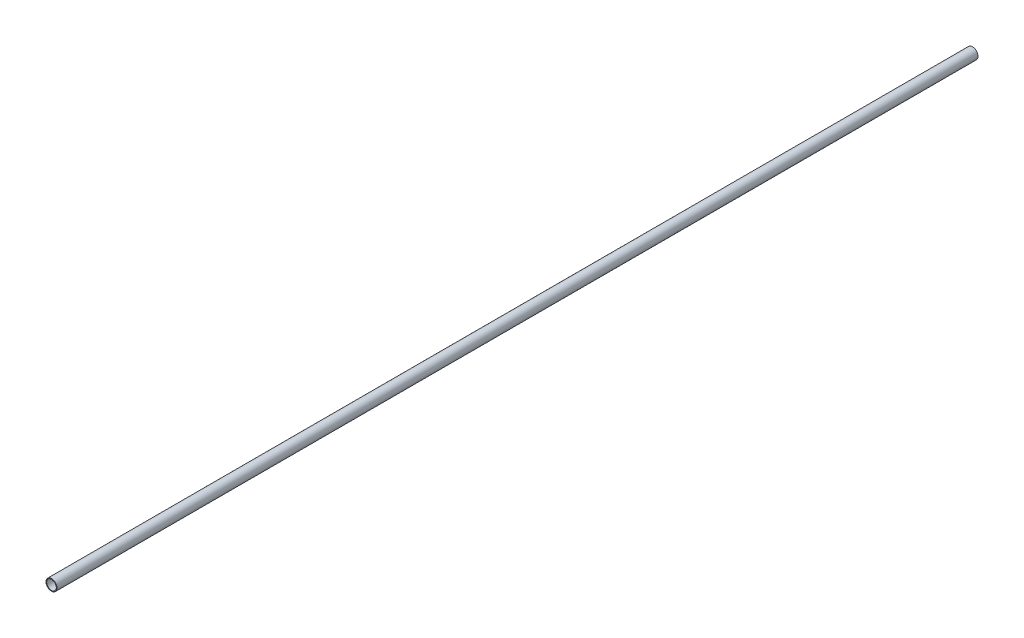
from build123d import *

# Parameters (mm, degrees)
SKETCH3_R                = 10.922
SKETCH3_R_2              = 9.525
BOSS_EXTRUDE1_DEPTH      = 914.4
BOSS_EXTRUDE1_DEPTH_BACK = 914.4


with BuildPart() as part:
    # Sketch3 → Boss-Extrude1 (new body, two sides)
    with BuildSketch(Plane.XY) as boss_extrude1_sk:
        Circle(SKETCH3_R)
        Circle(SKETCH3_R_2, mode=Mode.SUBTRACT)
    extrude(amount=BOSS_EXTRUDE1_DEPTH)
    extrude(boss_extrude1_sk.sketch, amount=-BOSS_EXTRUDE1_DEPTH_BACK)


solid = part.part
